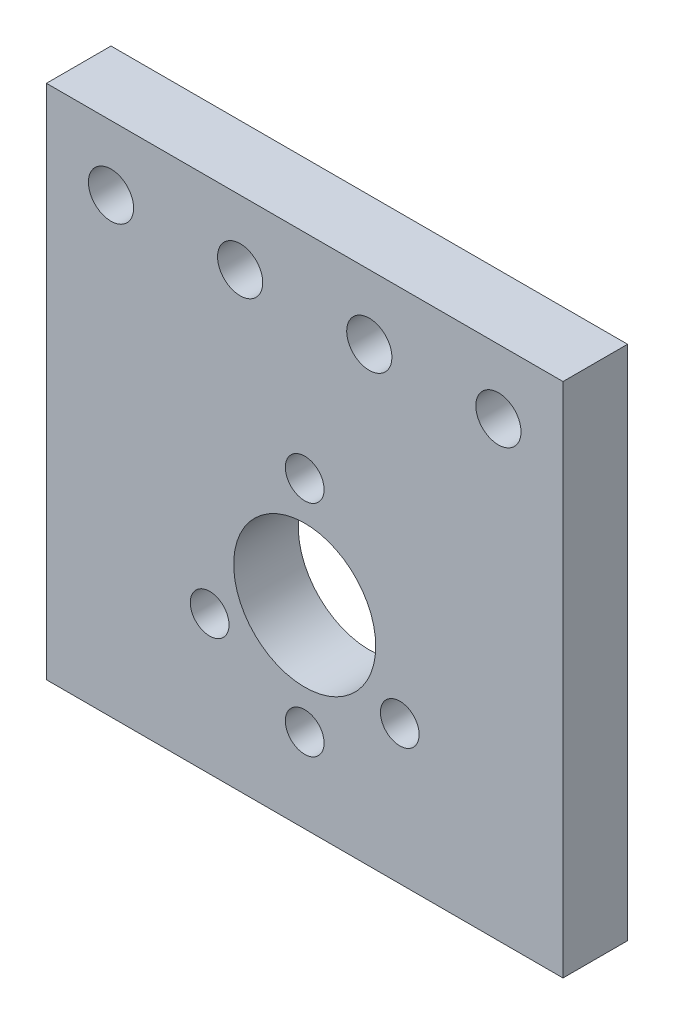
from build123d import *

# Parameters (mm, degrees)
SKETCH1_W           = 40
SKETCH1_H           = 40
SKETCH1_R           = 5.5
SKETCH1_R_2         = 1.5
SKETCH1_R_3         = 1.75
BOSS_EXTRUDE1_DEPTH = 5


with BuildPart() as part:
    # Sketch1 → Boss-Extrude1 (new body)
    with BuildSketch(Plane.XY):
        with Locations((0, 5)):
            Rectangle(SKETCH1_W, SKETCH1_H)
        Circle(SKETCH1_R, mode=Mode.SUBTRACT)
        with Locations((0, -8.5)):
            Circle(SKETCH1_R_2, mode=Mode.SUBTRACT)
        with Locations((0, 8.5)):
            Circle(SKETCH1_R_2, mode=Mode.SUBTRACT)
        with Locations((7.361215932, -4.25)):
            Circle(SKETCH1_R_2, mode=Mode.SUBTRACT)
        with Locations((-7.361215932, -4.25)):
            Circle(SKETCH1_R_2, mode=Mode.SUBTRACT)
        with Locations((-15, 20)):
            Circle(SKETCH1_R_3, mode=Mode.SUBTRACT)
        with Locations((-5, 20)):
            Circle(SKETCH1_R_3, mode=Mode.SUBTRACT)
        with Locations((5, 20)):
            Circle(SKETCH1_R_3, mode=Mode.SUBTRACT)
        with Locations((15, 20)):
            Circle(SKETCH1_R_3, mode=Mode.SUBTRACT)
    extrude(amount=BOSS_EXTRUDE1_DEPTH)


solid = part.part
